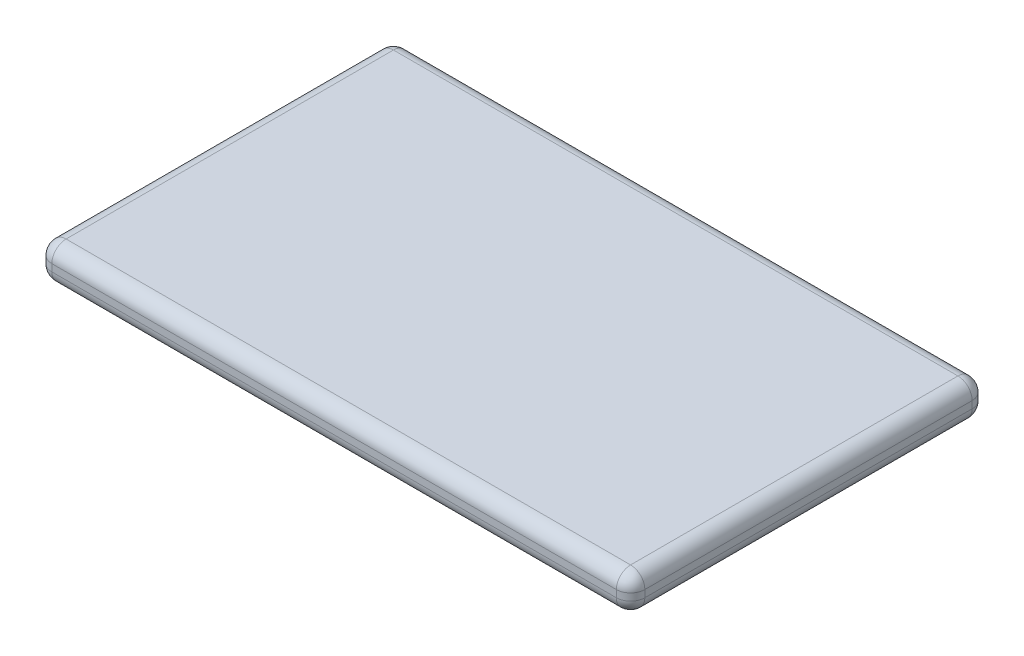
from build123d import *

# Parameters (mm, degrees)
SKETCH1_W           = 250
SKETCH1_H           = 150
BOSS_EXTRUDE1_DEPTH = 15
FILLET1_R           = 6


with BuildPart() as part:
    # Sketch1 → Boss-Extrude1 (new body)
    with BuildSketch(Plane(origin=(0, 0, 0), x_dir=(1, 0, 0), z_dir=(0, 1, 0))):
        Rectangle(SKETCH1_W, SKETCH1_H)
    extrude(amount=BOSS_EXTRUDE1_DEPTH)

    # Fillet1
    fillet1_edges = [part.edges().sort_by_distance(p)[0] for p in [
        (0, 15, 75),
        (-125, 15, 0),
        (0, 15, -75),
        (-125, 0, 0),
        (0, 0, 75),
        (125, 0, 0),
        (0, 0, -75),
        (-125, 7.5, -75),
        (-125, 7.5, 75),
        (125, 7.5, 75),
        (125, 7.5, -75),
        (125, 15, 0),
    ]]
    fillet(fillet1_edges, radius=FILLET1_R)


solid = part.part
